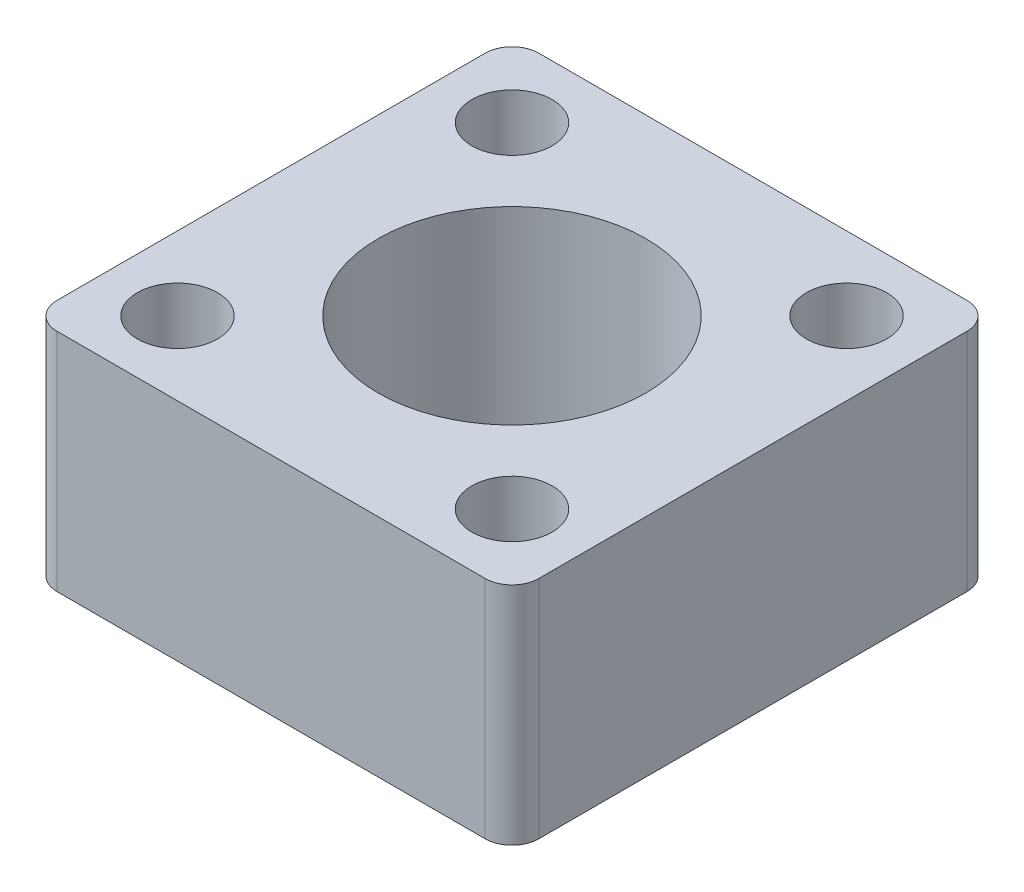
from build123d import *

# Parameters (mm, degrees)
SKETCH_1_W          = 36
SKETCH_1_H          = 16.85
EXTRUDE_1_DEPTH     = 36
SKETCH_2_R          = 3
CUT_EXTRUDE_1_DEPTH = 17.85
SKETCH_3_R          = 10
CUT_EXTRUDE_2_DEPTH = 17.85
FILLET_1_R          = 2


with BuildPart() as part:
    # 草图1 → 凸台-拉伸1 (new body)
    with BuildSketch(Plane.XY):
        Rectangle(SKETCH_1_W, SKETCH_1_H)
    extrude(amount=EXTRUDE_1_DEPTH)

    # 草图2 → 切除-拉伸1 (cut, through all)
    with BuildSketch(Plane(origin=(0, 8.425, 0), x_dir=(1, 0, 0), z_dir=(0, 1, 0))):
        with Locations((-12.5, -5.5)):
            Circle(SKETCH_2_R)
        with Locations((-12.5, -30.5)):
            Circle(SKETCH_2_R)
        with Locations((12.5, -30.5)):
            Circle(SKETCH_2_R)
        with Locations((12.5, -5.5)):
            Circle(SKETCH_2_R)
    extrude(amount=-CUT_EXTRUDE_1_DEPTH, mode=Mode.SUBTRACT)

    # 草图3 → 切除-拉伸2 (cut, through all)
    with BuildSketch(Plane(origin=(0, 8.425, 0), x_dir=(1, 0, 0), z_dir=(0, 1, 0))):
        with Locations((0, -18)):
            Circle(SKETCH_3_R)
    extrude(amount=-CUT_EXTRUDE_2_DEPTH, mode=Mode.SUBTRACT)

    # 圆角1
    fillet_1_edges = [part.edges().sort_by_distance(p)[0] for p in [
        (-18, 0, 36),
        (18, 0, 36),
        (-18, 0, 0),
        (18, 0, 0),
    ]]
    fillet(fillet_1_edges, radius=FILLET_1_R)


solid = part.part
